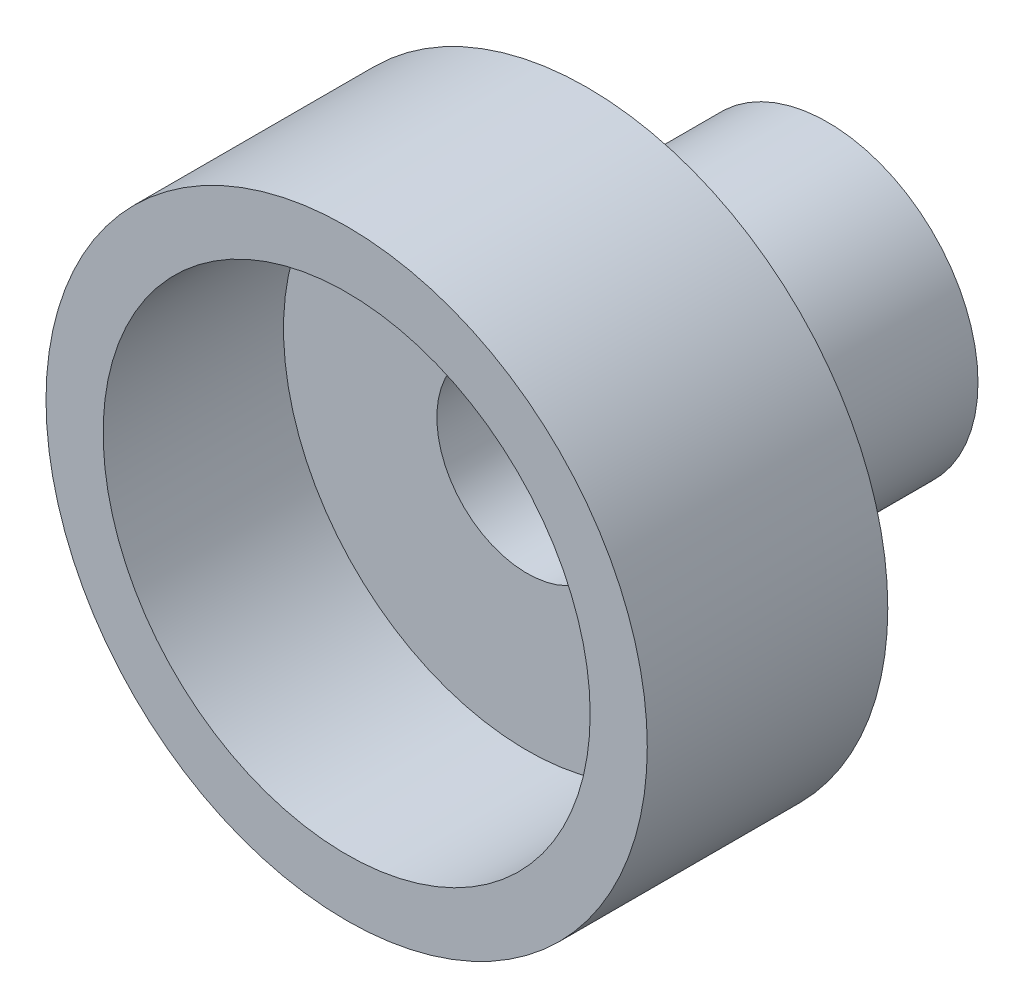
from build123d import *

# Parameters (mm, degrees)
SKETCH_1_R               = 5
EXTRUDE_1_DEPTH          = 4
SKETCH_4_R               = 2.5
EXTRUDE_2_DEPTH          = 4
SKETCH_2_R               = 1.5
CUT_EXTRUDE_1_DEPTH      = 4
CUT_EXTRUDE_1_DEPTH_BACK = 3
SKETCH_3_R               = 4.05
CUT_EXTRUDE_2_DEPTH      = 3


with BuildPart() as part:
    # 草图1 → 凸台-拉伸1 (new body)
    with BuildSketch(Plane.XY):
        Circle(SKETCH_1_R)
    extrude(amount=EXTRUDE_1_DEPTH)

    # 草图4 → 凸台-拉伸2 (add)
    with BuildSketch(Plane(origin=(0, 0, 0), x_dir=(-1, 0, 0), z_dir=(0, 0, -1))):
        Circle(SKETCH_4_R)
    extrude(amount=EXTRUDE_2_DEPTH)

    # 草图2 → 切除-拉伸1 (cut, two sides)
    with BuildSketch(Plane(origin=(0, 0, 0), x_dir=(-1, 0, 0), z_dir=(0, 0, -1))) as cut_extrude_1_sk:
        Circle(SKETCH_2_R)
    extrude(amount=CUT_EXTRUDE_1_DEPTH, mode=Mode.SUBTRACT)
    extrude(cut_extrude_1_sk.sketch, amount=-CUT_EXTRUDE_1_DEPTH_BACK, mode=Mode.SUBTRACT)

    # 草图3 → 切除-拉伸2 (cut)
    with BuildSketch(Plane.XY.offset(4)):
        Circle(SKETCH_3_R)
    extrude(amount=-CUT_EXTRUDE_2_DEPTH, mode=Mode.SUBTRACT)


solid = part.part
